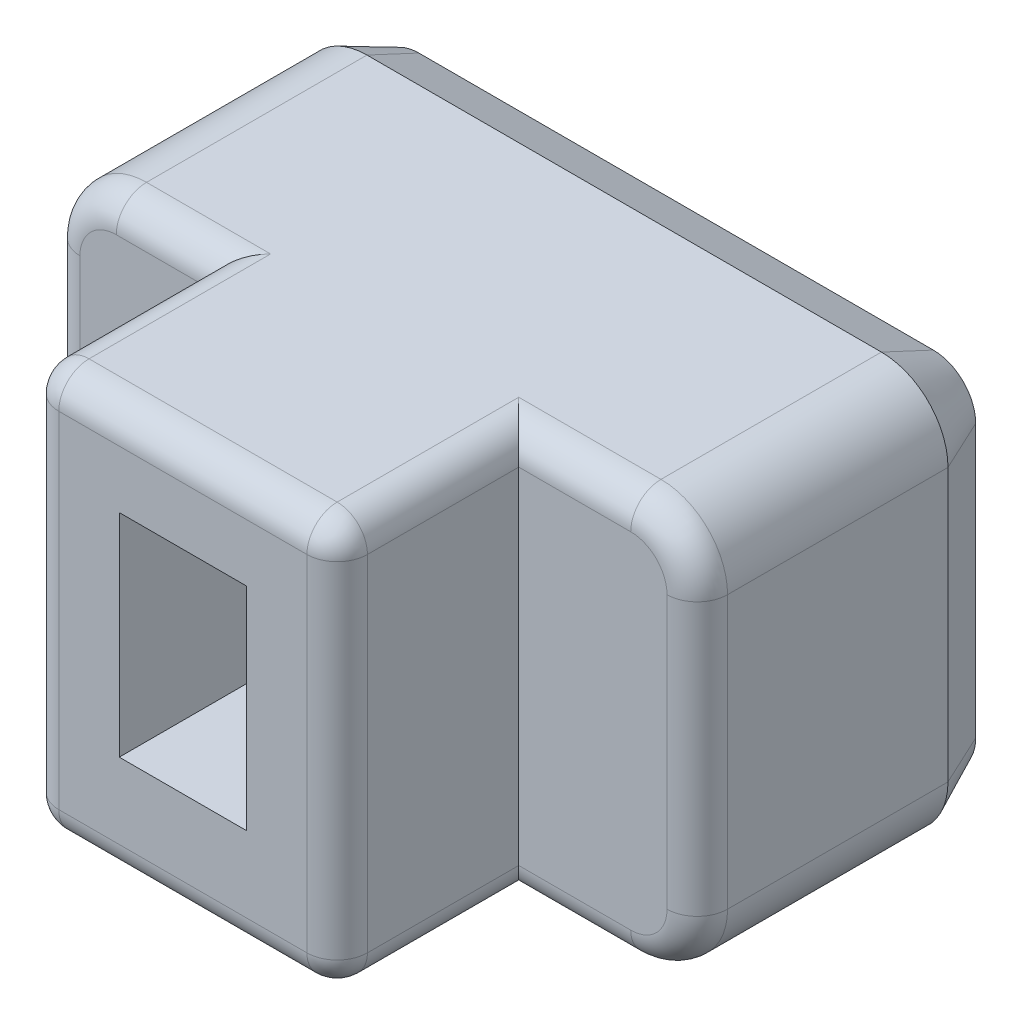
from build123d import *

# Parameters (mm, degrees)
BOSS_EXTRU_1_DEPTH      = 8
ESQUISSE3_W             = 2.1
ESQUISSE3_H             = 3.5
ENL_V_MAT_EXTRU_1_DEPTH = 3
ESQUISSE4_OUTSIDE_W     = 15.69
ESQUISSE4_OUTSIDE_H     = 11.69
ESQUISSE4_OUTSIDE_W_2   = 5.1
ESQUISSE4_OUTSIDE_H_2   = 6.7
ENL_V_MAT_EXTRU_2_DEPTH = 3
CONG_1_R                = 0.5
CHANFREIN1_SIZE         = 0.4
CHANFREIN1_SIZE2        = 0.857802768
ENL_V_MAT_EXTRU_3_DEPTH = 0.2
BOSS_EXTRU_2_DEPTH      = 0.2
BOSS_EXTRU_2_2_DEPTH    = 0.2
BOSS_EXTRU_2_3_DEPTH    = 0.2


with BuildPart() as part:
    # Esquisse2 → Boss.-Extru.1 (new body)
    with BuildSketch(Plane.XY):
        with BuildLine():
            Line((1.1, 0), (9.6, 0))
            ThreePointArc((9.6, 0), (10.377817459, 0.322182541), (10.7, 1.1))
            Line((10.7, 1.1), (10.7, 5.6))
            ThreePointArc((10.7, 5.6), (10.377817459, 6.377817459), (9.6, 6.7))
            Line((9.6, 6.7), (1.1, 6.7))
            ThreePointArc((1.1, 6.7), (0.322182541, 6.377817459), (0, 5.6))
            Line((0, 5.6), (0, 1.1))
            ThreePointArc((0, 1.1), (0.322182541, 0.322182541), (1.1, 0))
        make_face()
    extrude(amount=BOSS_EXTRU_1_DEPTH)

    # Esquisse3 → Enlèv. mat.-Extru.1 (cut)
    with BuildSketch(Plane.XY.offset(8)):
        with Locations((5.2, 3.5)):
            Rectangle(ESQUISSE3_W, ESQUISSE3_H)
    extrude(amount=-ENL_V_MAT_EXTRU_1_DEPTH, mode=Mode.SUBTRACT)

    # Esquisse4 outside → Enlèv. mat.-Extru.2 (cut)
    with BuildSketch(Plane.XY.offset(8)):
        with Locations((5.35, 3.35)):
            Rectangle(ESQUISSE4_OUTSIDE_W, ESQUISSE4_OUTSIDE_H)
        with Locations((5.2, 3.35)):
            Rectangle(ESQUISSE4_OUTSIDE_W_2, ESQUISSE4_OUTSIDE_H_2, mode=Mode.SUBTRACT)
    extrude(amount=-ENL_V_MAT_EXTRU_2_DEPTH, mode=Mode.SUBTRACT)

    # Congé1
    cong_1_edges = [part.edges().sort_by_distance(p)[0] for p in [
        (8.675, 0, 5),
        (10.377817459, 0.322182541, 5),
        (10.7, 3.35, 5),
        (10.377817459, 6.377817459, 5),
        (1.875, 6.7, 5),
        (0.322182541, 6.377817459, 5),
        (1.875, 0, 5),
        (0.322182541, 0.322182541, 5),
        (7.75, 6.7, 6.5),
        (2.65, 6.7, 6.5),
        (7.75, 0, 6.5),
        (2.65, 0, 6.5),
        (2.65, 3.35, 8),
        (5.2, 6.7, 8),
        (7.75, 3.35, 8),
        (5.2, 0, 8),
        (8.675, 6.7, 5),
        (0, 3.35, 5),
    ]]
    fillet(cong_1_edges, radius=CONG_1_R)

    # Chanfrein1
    chanfrein1_edges = [part.edges().sort_by_distance(p)[0] for p in [
        (5.35, 0, 0),
        (10.377817459, 0.322182541, 0),
        (0.322182541, 0.322182541, 0),
        (10.7, 3.35, 0),
        (0, 3.35, 0),
        (10.377817459, 6.377817459, 0),
        (0.322182541, 6.377817459, 0),
        (5.35, 6.7, 0),
    ]]
    chanfrein1_side = [part.faces().sort_by_distance(p)[0] for p in [
        (5.35, 3.35, 0),
    ]]
    chamfer(chanfrein1_edges, length=CHANFREIN1_SIZE, length2=CHANFREIN1_SIZE2, reference=chanfrein1_side[0])

    # Esquisse5 → Enlèv. mat.-Extru.3 (cut)
    with BuildSketch(Plane.XY):
        with BuildLine():
            Line((2.817514503, 5.092998901), (2.643134521, 5.092998901))
            Line((2.643134521, 5.092998901), (1.859587134, 3.00276418))
            add(Edge.make_bspline(
                [(1.859587134, 3.00276418), (1.832279684, 2.929203331), (1.776734704, 2.779576184), (1.695294228, 2.549651593), (1.613961671, 2.310390606), (1.56100836, 2.147204241), (1.534077833, 2.064212364)],
                knots=[0, 0, 0, 0, 0.947748737, 1.92777736, 2.946127352, 4, 4, 4, 4], degree=3))
            Line((1.534077833, 2.064212364), (1.515477302, 2.064212364))
            add(Edge.make_bspline(
                [(1.515477302, 2.064212364), (1.520372189, 2.183298666), (1.52994807, 2.416267545), (1.539870374, 2.758074298), (1.546440558, 3.084374398), (1.547507689, 3.296753009), (1.548028232, 3.40035054)],
                knots=[0, 0, 0, 0, 1.070029531, 2.093301887, 3.069919448, 4, 4, 4, 4], degree=3))
            Line((1.548028232, 3.40035054), (1.548028232, 5.092998901))
            Line((1.548028232, 5.092998901), (1.169042404, 5.092998901))
            Line((1.169042404, 5.092998901), (1.169042404, 1.592998901))
            Line((1.169042404, 1.592998901), (1.715433015, 1.592998901))
            Line((1.715433015, 1.592998901), (2.447828941, 3.573180478))
            add(Edge.make_bspline(
                [(2.447828941, 3.573180478), (2.469461533, 3.632790174), (2.514672823, 3.75737216), (2.581537011, 3.953750489), (2.653347136, 4.166553923), (2.700223151, 4.314793749), (2.724511846, 4.391603861)],
                knots=[0, 0, 0, 0, 0.880724255, 1.840679997, 2.881153501, 4, 4, 4, 4], degree=3))
            Line((2.724511846, 4.391603861), (2.736137178, 4.391603861))
            add(Edge.make_bspline(
                [(2.736137178, 4.391603861), (2.749853222, 4.348726933), (2.776538643, 4.265307186), (2.814999378, 4.143711322), (2.852026734, 4.029978215), (2.888071845, 3.923928876), (2.921903137, 3.825497195), (2.953554522, 3.734420835), (2.98408129, 3.651434256), (3.003521998, 3.598498531), (3.012820083, 3.573180478)],
                knots=[0, 0, 0, 0, 1.25043417, 2.432797927, 3.542461226, 4.57269138, 5.543954559, 6.43358805, 7.250817819, 8, 8, 8, 8], degree=3))
            Line((3.012820083, 3.573180478), (3.745216009, 1.592998901))
            Line((3.745216009, 1.592998901), (4.29160662, 1.592998901))
            Line((4.29160662, 1.592998901), (4.29160662, 5.092998901))
            Line((4.29160662, 5.092998901), (3.912620792, 5.092998901))
            Line((3.912620792, 5.092998901), (3.912620792, 3.40035054))
            add(Edge.make_bspline(
                [(3.912620792, 3.40035054), (3.913244903, 3.298305086), (3.914531118, 3.088001967), (3.919487375, 2.763216242), (3.931119671, 2.419904801), (3.940405694, 2.184852423), (3.945171722, 2.064212364)],
                knots=[0, 0, 0, 0, 0.916160818, 1.888094683, 2.916069754, 4, 4, 4, 4], degree=3))
            Line((3.945171722, 2.064212364), (3.92657119, 2.064212364))
            add(Edge.make_bspline(
                [(3.92657119, 2.064212364), (3.898264381, 2.150792486), (3.843351783, 2.318749931), (3.761739106, 2.562229465), (3.681029008, 2.788347748), (3.62705425, 2.933070672), (3.60106189, 3.00276418)],
                knots=[0, 0, 0, 0, 1.100235793, 2.134355898, 3.101570919, 4, 4, 4, 4], degree=3))
            Line((3.60106189, 3.00276418), (2.817514503, 5.092998901))
        make_face()
        with BuildLine():
            add(Edge.make_bspline(
                [(5.098094662, 2.519150362), (5.098479457, 2.543748085), (5.09922086, 2.591141743), (5.110708693, 2.658611592), (5.12686521, 2.720081012), (5.152521237, 2.774107358), (5.183320539, 2.822524502), (5.217813855, 2.867261442), (5.258966696, 2.906041268), (5.319845774, 2.953064911), (5.40712664, 3.003717061), (5.524214642, 3.049957606), (5.650661745, 3.089057507), (5.737434065, 3.113522336), (5.781664193, 3.125992701)],
                knots=[0, 0, 0, 0, 0.880486965, 1.696478074, 2.446944501, 3.151258593, 3.829523831, 4.502012172, 5.170022751, 5.849803385, 7.256908892, 8.768459035, 10.352798764, 12, 12, 12, 12], degree=3))
            add(Edge.make_bspline(
                [(5.781664193, 3.125992701), (5.841670808, 3.143040851), (5.961479939, 3.177079168), (6.109572139, 3.223336728), (6.224033353, 3.267189913), (6.304744542, 3.305887287), (6.380604036, 3.350604981), (6.45214516, 3.400489678), (6.51780868, 3.458307302), (6.576985073, 3.523894814), (6.629857882, 3.597092218), (6.676294211, 3.678501859), (6.714370019, 3.770574703), (6.739724001, 3.874815211), (6.75533472, 3.990961756), (6.757208254, 4.072239826), (6.758192094, 4.114920956)],
                knots=[0, 0, 0, 0, 1.706742266, 3.407679468, 4.242430161, 5.058020634, 5.853204933, 6.649362358, 7.440579056, 8.241210102, 9.061198638, 9.906297875, 10.800118187, 11.777216625, 12.832761325, 14, 14, 14, 14], degree=3))
            add(Edge.make_bspline(
                [(6.758192094, 4.114920956), (6.757281991, 4.158640741), (6.75551355, 4.24359362), (6.738141025, 4.366171328), (6.710490827, 4.479547926), (6.671691889, 4.583782776), (6.621625705, 4.678086074), (6.564127378, 4.764673025), (6.496883827, 4.841689789), (6.421232518, 4.910411115), (6.337018387, 4.970175567), (6.245174829, 5.021337872), (6.145678785, 5.064275045), (6.038886306, 5.098570422), (5.925720424, 5.125952695), (5.806900789, 5.143750956), (5.683236236, 5.15607339), (5.599049221, 5.157416219), (5.556132749, 5.158100761)],
                knots=[0, 0, 0, 0, 1.159127606, 2.252326411, 3.27615946, 4.249869671, 5.193974946, 6.102490449, 7.001157183, 7.898673524, 8.807628291, 9.734160275, 10.682583241, 11.677288198, 12.706154421, 13.767464238, 14.861908121, 16, 16, 16, 16], degree=3))
            add(Edge.make_bspline(
                [(5.556132749, 5.158100761), (5.515275958, 5.157475502), (5.432576117, 5.156209892), (5.30870202, 5.141961731), (5.186347468, 5.12235001), (5.068980211, 5.096693443), (4.959641152, 5.06755058), (4.862708119, 5.032588899), (4.779659616, 4.99836097), (4.733039646, 4.969525727), (4.712133635, 4.956595004)],
                knots=[0, 0, 0, 0, 1.117668173, 2.262316179, 3.408404461, 4.508127461, 5.549289101, 6.501919885, 7.328208939, 8, 8, 8, 8], degree=3))
            Line((4.712133635, 4.956595004), (4.712133635, 4.567533888))
            add(Edge.make_bspline(
                [(4.712133635, 4.567533888), (4.741616057, 4.582997837), (4.802810542, 4.615095215), (4.901677609, 4.655013594), (5.006863124, 4.691364968), (5.116696761, 4.721344229), (5.22883485, 4.745119233), (5.340807343, 4.763351298), (5.449890722, 4.776918423), (5.521477297, 4.778398446), (5.556132749, 4.779114933)],
                knots=[0, 0, 0, 0, 0.909703881, 1.88820511, 2.911196513, 3.951283487, 4.998564079, 6.043603477, 7.052897759, 8, 8, 8, 8], degree=3))
            add(Edge.make_bspline(
                [(5.556132749, 4.779114933), (5.609197966, 4.777783095), (5.713568373, 4.775163592), (5.840947065, 4.753991765), (5.937798712, 4.731200377), (6.004602927, 4.706425596), (6.067725527, 4.678173866), (6.126013988, 4.643993945), (6.179562574, 4.604255999), (6.2272238, 4.557469175), (6.268439515, 4.503175419), (6.304323887, 4.442558272), (6.333477098, 4.374497247), (6.353111034, 4.298206668), (6.365817786, 4.214292782), (6.366978027, 4.15553109), (6.367580934, 4.124996244)],
                knots=[0, 0, 0, 0, 1.87034002, 3.678646016, 4.542823419, 5.375882515, 6.187380047, 6.979772314, 7.754358122, 8.534072985, 9.326936712, 10.152133513, 11.013664266, 11.928806421, 12.92372774, 14, 14, 14, 14], degree=3))
            add(Edge.make_bspline(
                [(6.367580934, 4.124996244), (6.36677873, 4.099903198), (6.36525, 4.052084319), (6.355302522, 3.983297326), (6.337883497, 3.92135971), (6.312506047, 3.865989077), (6.281024385, 3.817013623), (6.245041056, 3.772165029), (6.203970807, 3.732117974), (6.142754834, 3.683737571), (6.05497561, 3.632852992), (5.93716984, 3.58613705), (5.809563116, 3.547390216), (5.721776296, 3.52289006), (5.677036204, 3.510403684)],
                knots=[0, 0, 0, 0, 0.889177509, 1.694472311, 2.456508881, 3.161117673, 3.844288232, 4.514829322, 5.194556335, 5.872245921, 7.275862128, 8.770198597, 10.353948627, 12, 12, 12, 12], degree=3))
            add(Edge.make_bspline(
                [(5.677036204, 3.510403684), (5.617274334, 3.493921983), (5.498442652, 3.461149444), (5.35177786, 3.415770238), (5.238551835, 3.373096155), (5.158637345, 3.335139901), (5.083468337, 3.291295308), (5.012967187, 3.241825996), (4.947130117, 3.186160003), (4.888720575, 3.121984205), (4.837299312, 3.05014798), (4.792987967, 2.970440013), (4.75515425, 2.881629678), (4.730805865, 2.780877948), (4.714982376, 2.669231771), (4.713111584, 2.591030573), (4.712133635, 2.550151248)],
                knots=[0, 0, 0, 0, 1.731440325, 3.44283011, 4.285652068, 5.108629109, 5.910524492, 6.713230969, 7.511482537, 8.313280534, 9.130226032, 9.973295025, 10.856326095, 11.817060712, 12.858878303, 14, 14, 14, 14], degree=3))
            add(Edge.make_bspline(
                [(4.712133635, 2.550151248), (4.7131776, 2.507220521), (4.715197329, 2.424163689), (4.730617138, 2.304132404), (4.75684638, 2.193434966), (4.793408913, 2.091816425), (4.839304675, 1.999626679), (4.892625974, 1.915317032), (4.953530304, 1.839426682), (5.022635183, 1.772300655), (5.097860725, 1.713095973), (5.179851889, 1.662904624), (5.267228055, 1.619471659), (5.361111342, 1.586059495), (5.459140733, 1.559876835), (5.560710372, 1.541135899), (5.665430722, 1.530280641), (5.736429661, 1.528698035), (5.772363927, 1.527897041)],
                knots=[0, 0, 0, 0, 1.234756564, 2.3888477, 3.473975945, 4.501297612, 5.488398123, 6.43058259, 7.366060614, 8.280490487, 9.196278313, 10.114024079, 11.041318885, 11.99816134, 12.975223422, 13.957668963, 14.966327269, 16, 16, 16, 16], degree=3))
            add(Edge.make_bspline(
                [(5.772363927, 1.527897041), (5.813202891, 1.528414894), (5.89346077, 1.529432593), (6.011763265, 1.539768451), (6.12586223, 1.556836295), (6.235786883, 1.580122977), (6.341108978, 1.608613118), (6.441663931, 1.64265071), (6.53827749, 1.678947205), (6.599989789, 1.707582175), (6.63031344, 1.721652577)],
                knots=[0, 0, 0, 0, 1.104714536, 2.171016076, 3.209933901, 4.224369017, 5.209509432, 6.159944183, 7.095849437, 8, 8, 8, 8], degree=3))
            Line((6.63031344, 1.721652577), (6.63031344, 2.116138848))
            add(Edge.make_bspline(
                [(6.63031344, 2.116138848), (6.565418934, 2.08731366), (6.435678099, 2.029684684), (6.266108425, 1.975243545), (6.126939492, 1.939879235), (6.01787458, 1.92322185), (5.905736878, 1.909636109), (5.829501089, 1.907807312), (5.790964459, 1.906882869)],
                knots=[0, 0, 0, 0, 1.464993217, 2.928898808, 3.670070941, 4.426719255, 5.204718158, 6, 6, 6, 6], degree=3))
            add(Edge.make_bspline(
                [(5.790964459, 1.906882869), (5.762536693, 1.907604431), (5.707382707, 1.909004366), (5.62742592, 1.916153316), (5.553472027, 1.930620029), (5.484972538, 1.948563605), (5.422392103, 1.973137211), (5.365196755, 2.001470654), (5.31332111, 2.034247574), (5.267219743, 2.071664837), (5.226632942, 2.113832812), (5.191577957, 2.160336005), (5.162799591, 2.211662553), (5.138683453, 2.266633945), (5.120366339, 2.325442132), (5.107035799, 2.387414195), (5.099241461, 2.452295992), (5.098480562, 2.496653785), (5.098094662, 2.519150362)],
                knots=[0, 0, 0, 0, 1.296243822, 2.514900931, 3.653549349, 4.727708741, 5.738067187, 6.712369634, 7.633630829, 8.529322939, 9.412149162, 10.295368015, 11.176149746, 12.088486272, 13.027046857, 13.978667069, 14.974857196, 16, 16, 16, 16], degree=3))
        make_face()
        with BuildLine():
            Line((9.195326726, 3.677808467), (8.486181465, 3.677808467))
            Line((8.486181465, 3.677808467), (8.486181465, 3.293397484))
            Line((8.486181465, 3.293397484), (9.574312554, 3.293397484))
            Line((9.574312554, 3.293397484), (9.574312554, 4.986045845))
            add(Edge.make_bspline(
                [(9.574312554, 4.986045845), (9.554337903, 4.996016127), (9.508309318, 5.018991145), (9.425997353, 5.046664397), (9.326767081, 5.075532661), (9.212918745, 5.102247351), (9.088734823, 5.126535451), (8.956184263, 5.143603958), (8.820440785, 5.155856582), (8.729048426, 5.157357737), (8.683812112, 5.158100761)],
                knots=[0, 0, 0, 0, 0.585979414, 1.350301529, 2.276132354, 3.301802694, 4.421346687, 5.59920706, 6.811683744, 8, 8, 8, 8], degree=3))
            add(Edge.make_bspline(
                [(8.683812112, 5.158100761), (8.619148494, 5.156709547), (8.49300037, 5.153995517), (8.310160046, 5.130163786), (8.13844067, 5.092964042), (7.979456218, 5.037919862), (7.831435735, 4.971129826), (7.696488355, 4.889503772), (7.572987937, 4.796645688), (7.463107688, 4.689445276), (7.366063654, 4.569921884), (7.279718683, 4.439099064), (7.208209438, 4.294780042), (7.148414287, 4.139642686), (7.10250499, 3.973907841), (7.067845736, 3.799158239), (7.048934363, 3.614673902), (7.046092718, 3.488742886), (7.044640278, 3.424376226)],
                knots=[0, 0, 0, 0, 1.146148901, 2.235948753, 3.263977738, 4.256307499, 5.213590835, 6.138269925, 7.047143522, 7.947736641, 8.852792543, 9.772682079, 10.721211655, 11.702953654, 12.716665434, 13.766898494, 14.858603004, 16, 16, 16, 16], degree=3))
            add(Edge.make_bspline(
                [(7.044640278, 3.424376226), (7.046063576, 3.354300357), (7.048844883, 3.21736304), (7.072535425, 3.016612658), (7.111842754, 2.826044903), (7.166207315, 2.645564588), (7.234041196, 2.476480104), (7.315747278, 2.319604891), (7.410735069, 2.175623208), (7.517693111, 2.044195798), (7.636911901, 1.926389957), (7.767828093, 1.82299762), (7.909496666, 1.733292142), (8.061866497, 1.658987872), (8.223520824, 1.599637052), (8.39405789, 1.558111033), (8.572480471, 1.532774358), (8.694061405, 1.529541203), (8.755889171, 1.527897041)],
                knots=[0, 0, 0, 0, 1.170978058, 2.288242658, 3.373061366, 4.419447092, 5.43457523, 6.413784157, 7.370679712, 8.312808504, 9.241030757, 10.166265276, 11.09588253, 12.038278457, 12.994501538, 13.968469652, 14.966902308, 16, 16, 16, 16], degree=3))
            add(Edge.make_bspline(
                [(8.755889171, 1.527897041), (8.789994557, 1.528445553), (8.858259087, 1.529543442), (8.959990706, 1.535241084), (9.059140273, 1.547474272), (9.154194187, 1.561494817), (9.243340484, 1.580377517), (9.325308622, 1.601309301), (9.397408333, 1.625337025), (9.440613547, 1.644624609), (9.460384299, 1.653450628)],
                knots=[0, 0, 0, 0, 1.136075315, 2.27394134, 3.391388784, 4.462283479, 5.473109321, 6.424781878, 7.279178486, 8, 8, 8, 8], degree=3))
            Line((9.460384299, 1.653450628), (9.460384299, 2.03011139))
            add(Edge.make_bspline(
                [(9.460384299, 2.03011139), (9.436477281, 2.021216258), (9.387112841, 2.002849134), (9.308852946, 1.981876261), (9.226399112, 1.958931325), (9.109238471, 1.935175858), (8.95906135, 1.911477231), (8.837374156, 1.908409546), (8.776814769, 1.906882869)],
                knots=[0, 0, 0, 0, 0.65742795, 1.357490991, 2.087898976, 2.864030287, 4.439339425, 6, 6, 6, 6], degree=3))
            add(Edge.make_bspline(
                [(8.776814769, 1.906882869), (8.73309505, 1.907832375), (8.646349541, 1.909716317), (8.518021322, 1.92765633), (8.39261655, 1.955243693), (8.270855131, 1.994867158), (8.153729798, 2.04569206), (8.043442846, 2.108781533), (7.93995472, 2.182927149), (7.844637741, 2.269512843), (7.756449948, 2.367025534), (7.67926521, 2.477553323), (7.609401329, 2.598164836), (7.550954692, 2.731319812), (7.502238837, 2.875733898), (7.468729147, 3.032496165), (7.448405384, 3.200890558), (7.445863796, 3.31710454), (7.444551704, 3.377099875)],
                knots=[0, 0, 0, 0, 0.939117775, 1.863329679, 2.779299697, 3.695824843, 4.610784674, 5.51843797, 6.421392248, 7.34127464, 8.280966674, 9.240717944, 10.23307823, 11.272042469, 12.360603596, 13.503011429, 14.710932506, 16, 16, 16, 16], degree=3))
            add(Edge.make_bspline(
                [(7.444551704, 3.377099875), (7.445421, 3.435793474), (7.447098508, 3.549056324), (7.464772977, 3.712750977), (7.491644211, 3.864173966), (7.531542178, 4.003126934), (7.581261211, 4.129830741), (7.639368607, 4.245819722), (7.707439042, 4.350143479), (7.785846886, 4.442231757), (7.872402683, 4.523739913), (7.968203701, 4.593723734), (8.072807596, 4.652319418), (8.186083995, 4.698392677), (8.306177671, 4.73494513), (8.433410226, 4.76014165), (8.56689956, 4.775996038), (8.658190694, 4.778061703), (8.704737709, 4.779114933)],
                knots=[0, 0, 0, 0, 1.309777504, 2.527518125, 3.6711271, 4.738994566, 5.748914077, 6.705800728, 7.630353787, 8.522389362, 9.39963012, 10.278613241, 11.164231144, 12.069241185, 13.003350139, 13.96247614, 14.961118681, 16, 16, 16, 16], degree=3))
            add(Edge.make_bspline(
                [(8.704737709, 4.779114933), (8.748694815, 4.778484222), (8.836269585, 4.77722767), (8.964208569, 4.763822027), (9.084535915, 4.747315095), (9.159809318, 4.727848452), (9.195326726, 4.718663206)],
                knots=[0, 0, 0, 0, 1.063710201, 2.1192063, 3.112556144, 4, 4, 4, 4], degree=3))
            Line((9.195326726, 4.718663206), (9.195326726, 3.677808467))
        make_face()
    extrude(amount=ENL_V_MAT_EXTRU_3_DEPTH, mode=Mode.SUBTRACT)


with BuildPart() as body_2:
    # Esquisse5_4 → Boss.-Extru.2 (new body)
    with BuildSketch(Plane.XY):
        with BuildLine():
            Line((2.817514503, 5.092998901), (2.643134521, 5.092998901))
            Line((2.643134521, 5.092998901), (1.859587134, 3.00276418))
            add(Edge.make_bspline(
                [(1.859587134, 3.00276418), (1.832279684, 2.929203331), (1.776734704, 2.779576184), (1.695294228, 2.549651593), (1.613961671, 2.310390606), (1.56100836, 2.147204241), (1.534077833, 2.064212364)],
                knots=[0, 0, 0, 0, 0.947748737, 1.92777736, 2.946127352, 4, 4, 4, 4], degree=3))
            Line((1.534077833, 2.064212364), (1.515477302, 2.064212364))
            add(Edge.make_bspline(
                [(1.515477302, 2.064212364), (1.520372189, 2.183298666), (1.52994807, 2.416267545), (1.539870374, 2.758074298), (1.546440558, 3.084374398), (1.547507689, 3.296753009), (1.548028232, 3.40035054)],
                knots=[0, 0, 0, 0, 1.070029531, 2.093301887, 3.069919448, 4, 4, 4, 4], degree=3))
            Line((1.548028232, 3.40035054), (1.548028232, 5.092998901))
            Line((1.548028232, 5.092998901), (1.169042404, 5.092998901))
            Line((1.169042404, 5.092998901), (1.169042404, 1.592998901))
            Line((1.169042404, 1.592998901), (1.715433015, 1.592998901))
            Line((1.715433015, 1.592998901), (2.447828941, 3.573180478))
            add(Edge.make_bspline(
                [(2.447828941, 3.573180478), (2.469461533, 3.632790174), (2.514672823, 3.75737216), (2.581537011, 3.953750489), (2.653347136, 4.166553923), (2.700223151, 4.314793749), (2.724511846, 4.391603861)],
                knots=[0, 0, 0, 0, 0.880724255, 1.840679997, 2.881153501, 4, 4, 4, 4], degree=3))
            Line((2.724511846, 4.391603861), (2.736137178, 4.391603861))
            add(Edge.make_bspline(
                [(2.736137178, 4.391603861), (2.749853222, 4.348726933), (2.776538643, 4.265307186), (2.814999378, 4.143711322), (2.852026734, 4.029978215), (2.888071845, 3.923928876), (2.921903137, 3.825497195), (2.953554522, 3.734420835), (2.98408129, 3.651434256), (3.003521998, 3.598498531), (3.012820083, 3.573180478)],
                knots=[0, 0, 0, 0, 1.25043417, 2.432797927, 3.542461226, 4.57269138, 5.543954559, 6.43358805, 7.250817819, 8, 8, 8, 8], degree=3))
            Line((3.012820083, 3.573180478), (3.745216009, 1.592998901))
            Line((3.745216009, 1.592998901), (4.29160662, 1.592998901))
            Line((4.29160662, 1.592998901), (4.29160662, 5.092998901))
            Line((4.29160662, 5.092998901), (3.912620792, 5.092998901))
            Line((3.912620792, 5.092998901), (3.912620792, 3.40035054))
            add(Edge.make_bspline(
                [(3.912620792, 3.40035054), (3.913244903, 3.298305086), (3.914531118, 3.088001967), (3.919487375, 2.763216242), (3.931119671, 2.419904801), (3.940405694, 2.184852423), (3.945171722, 2.064212364)],
                knots=[0, 0, 0, 0, 0.916160818, 1.888094683, 2.916069754, 4, 4, 4, 4], degree=3))
            Line((3.945171722, 2.064212364), (3.92657119, 2.064212364))
            add(Edge.make_bspline(
                [(3.92657119, 2.064212364), (3.898264381, 2.150792486), (3.843351783, 2.318749931), (3.761739106, 2.562229465), (3.681029008, 2.788347748), (3.62705425, 2.933070672), (3.60106189, 3.00276418)],
                knots=[0, 0, 0, 0, 1.100235793, 2.134355898, 3.101570919, 4, 4, 4, 4], degree=3))
            Line((3.60106189, 3.00276418), (2.817514503, 5.092998901))
        make_face()
    extrude(amount=-BOSS_EXTRU_2_DEPTH)


with BuildPart() as body_3:
    # Esquisse5_4 → Boss.-Extru.2 2 (new body)
    with BuildSketch(Plane.XY):
        with BuildLine():
            add(Edge.make_bspline(
                [(5.098094662, 2.519150362), (5.098479457, 2.543748085), (5.09922086, 2.591141743), (5.110708693, 2.658611592), (5.12686521, 2.720081012), (5.152521237, 2.774107358), (5.183320539, 2.822524502), (5.217813855, 2.867261442), (5.258966696, 2.906041268), (5.319845774, 2.953064911), (5.40712664, 3.003717061), (5.524214642, 3.049957606), (5.650661745, 3.089057507), (5.737434065, 3.113522336), (5.781664193, 3.125992701)],
                knots=[0, 0, 0, 0, 0.880486965, 1.696478074, 2.446944501, 3.151258593, 3.829523831, 4.502012172, 5.170022751, 5.849803385, 7.256908892, 8.768459035, 10.352798764, 12, 12, 12, 12], degree=3))
            add(Edge.make_bspline(
                [(5.781664193, 3.125992701), (5.841670808, 3.143040851), (5.961479939, 3.177079168), (6.109572139, 3.223336728), (6.224033353, 3.267189913), (6.304744542, 3.305887287), (6.380604036, 3.350604981), (6.45214516, 3.400489678), (6.51780868, 3.458307302), (6.576985073, 3.523894814), (6.629857882, 3.597092218), (6.676294211, 3.678501859), (6.714370019, 3.770574703), (6.739724001, 3.874815211), (6.75533472, 3.990961756), (6.757208254, 4.072239826), (6.758192094, 4.114920956)],
                knots=[0, 0, 0, 0, 1.706742266, 3.407679468, 4.242430161, 5.058020634, 5.853204933, 6.649362358, 7.440579056, 8.241210102, 9.061198638, 9.906297875, 10.800118187, 11.777216625, 12.832761325, 14, 14, 14, 14], degree=3))
            add(Edge.make_bspline(
                [(6.758192094, 4.114920956), (6.757281991, 4.158640741), (6.75551355, 4.24359362), (6.738141025, 4.366171328), (6.710490827, 4.479547926), (6.671691889, 4.583782776), (6.621625705, 4.678086074), (6.564127378, 4.764673025), (6.496883827, 4.841689789), (6.421232518, 4.910411115), (6.337018387, 4.970175567), (6.245174829, 5.021337872), (6.145678785, 5.064275045), (6.038886306, 5.098570422), (5.925720424, 5.125952695), (5.806900789, 5.143750956), (5.683236236, 5.15607339), (5.599049221, 5.157416219), (5.556132749, 5.158100761)],
                knots=[0, 0, 0, 0, 1.159127606, 2.252326411, 3.27615946, 4.249869671, 5.193974946, 6.102490449, 7.001157183, 7.898673524, 8.807628291, 9.734160275, 10.682583241, 11.677288198, 12.706154421, 13.767464238, 14.861908121, 16, 16, 16, 16], degree=3))
            add(Edge.make_bspline(
                [(5.556132749, 5.158100761), (5.515275958, 5.157475502), (5.432576117, 5.156209892), (5.30870202, 5.141961731), (5.186347468, 5.12235001), (5.068980211, 5.096693443), (4.959641152, 5.06755058), (4.862708119, 5.032588899), (4.779659616, 4.99836097), (4.733039646, 4.969525727), (4.712133635, 4.956595004)],
                knots=[0, 0, 0, 0, 1.117668173, 2.262316179, 3.408404461, 4.508127461, 5.549289101, 6.501919885, 7.328208939, 8, 8, 8, 8], degree=3))
            Line((4.712133635, 4.956595004), (4.712133635, 4.567533888))
            add(Edge.make_bspline(
                [(4.712133635, 4.567533888), (4.741616057, 4.582997837), (4.802810542, 4.615095215), (4.901677609, 4.655013594), (5.006863124, 4.691364968), (5.116696761, 4.721344229), (5.22883485, 4.745119233), (5.340807343, 4.763351298), (5.449890722, 4.776918423), (5.521477297, 4.778398446), (5.556132749, 4.779114933)],
                knots=[0, 0, 0, 0, 0.909703881, 1.88820511, 2.911196513, 3.951283487, 4.998564079, 6.043603477, 7.052897759, 8, 8, 8, 8], degree=3))
            add(Edge.make_bspline(
                [(5.556132749, 4.779114933), (5.609197966, 4.777783095), (5.713568373, 4.775163592), (5.840947065, 4.753991765), (5.937798712, 4.731200377), (6.004602927, 4.706425596), (6.067725527, 4.678173866), (6.126013988, 4.643993945), (6.179562574, 4.604255999), (6.2272238, 4.557469175), (6.268439515, 4.503175419), (6.304323887, 4.442558272), (6.333477098, 4.374497247), (6.353111034, 4.298206668), (6.365817786, 4.214292782), (6.366978027, 4.15553109), (6.367580934, 4.124996244)],
                knots=[0, 0, 0, 0, 1.87034002, 3.678646016, 4.542823419, 5.375882515, 6.187380047, 6.979772314, 7.754358122, 8.534072985, 9.326936712, 10.152133513, 11.013664266, 11.928806421, 12.92372774, 14, 14, 14, 14], degree=3))
            add(Edge.make_bspline(
                [(6.367580934, 4.124996244), (6.36677873, 4.099903198), (6.36525, 4.052084319), (6.355302522, 3.983297326), (6.337883497, 3.92135971), (6.312506047, 3.865989077), (6.281024385, 3.817013623), (6.245041056, 3.772165029), (6.203970807, 3.732117974), (6.142754834, 3.683737571), (6.05497561, 3.632852992), (5.93716984, 3.58613705), (5.809563116, 3.547390216), (5.721776296, 3.52289006), (5.677036204, 3.510403684)],
                knots=[0, 0, 0, 0, 0.889177509, 1.694472311, 2.456508881, 3.161117673, 3.844288232, 4.514829322, 5.194556335, 5.872245921, 7.275862128, 8.770198597, 10.353948627, 12, 12, 12, 12], degree=3))
            add(Edge.make_bspline(
                [(5.677036204, 3.510403684), (5.617274334, 3.493921983), (5.498442652, 3.461149444), (5.35177786, 3.415770238), (5.238551835, 3.373096155), (5.158637345, 3.335139901), (5.083468337, 3.291295308), (5.012967187, 3.241825996), (4.947130117, 3.186160003), (4.888720575, 3.121984205), (4.837299312, 3.05014798), (4.792987967, 2.970440013), (4.75515425, 2.881629678), (4.730805865, 2.780877948), (4.714982376, 2.669231771), (4.713111584, 2.591030573), (4.712133635, 2.550151248)],
                knots=[0, 0, 0, 0, 1.731440325, 3.44283011, 4.285652068, 5.108629109, 5.910524492, 6.713230969, 7.511482537, 8.313280534, 9.130226032, 9.973295025, 10.856326095, 11.817060712, 12.858878303, 14, 14, 14, 14], degree=3))
            add(Edge.make_bspline(
                [(4.712133635, 2.550151248), (4.7131776, 2.507220521), (4.715197329, 2.424163689), (4.730617138, 2.304132404), (4.75684638, 2.193434966), (4.793408913, 2.091816425), (4.839304675, 1.999626679), (4.892625974, 1.915317032), (4.953530304, 1.839426682), (5.022635183, 1.772300655), (5.097860725, 1.713095973), (5.179851889, 1.662904624), (5.267228055, 1.619471659), (5.361111342, 1.586059495), (5.459140733, 1.559876835), (5.560710372, 1.541135899), (5.665430722, 1.530280641), (5.736429661, 1.528698035), (5.772363927, 1.527897041)],
                knots=[0, 0, 0, 0, 1.234756564, 2.3888477, 3.473975945, 4.501297612, 5.488398123, 6.43058259, 7.366060614, 8.280490487, 9.196278313, 10.114024079, 11.041318885, 11.99816134, 12.975223422, 13.957668963, 14.966327269, 16, 16, 16, 16], degree=3))
            add(Edge.make_bspline(
                [(5.772363927, 1.527897041), (5.813202891, 1.528414894), (5.89346077, 1.529432593), (6.011763265, 1.539768451), (6.12586223, 1.556836295), (6.235786883, 1.580122977), (6.341108978, 1.608613118), (6.441663931, 1.64265071), (6.53827749, 1.678947205), (6.599989789, 1.707582175), (6.63031344, 1.721652577)],
                knots=[0, 0, 0, 0, 1.104714536, 2.171016076, 3.209933901, 4.224369017, 5.209509432, 6.159944183, 7.095849437, 8, 8, 8, 8], degree=3))
            Line((6.63031344, 1.721652577), (6.63031344, 2.116138848))
            add(Edge.make_bspline(
                [(6.63031344, 2.116138848), (6.565418934, 2.08731366), (6.435678099, 2.029684684), (6.266108425, 1.975243545), (6.126939492, 1.939879235), (6.01787458, 1.92322185), (5.905736878, 1.909636109), (5.829501089, 1.907807312), (5.790964459, 1.906882869)],
                knots=[0, 0, 0, 0, 1.464993217, 2.928898808, 3.670070941, 4.426719255, 5.204718158, 6, 6, 6, 6], degree=3))
            add(Edge.make_bspline(
                [(5.790964459, 1.906882869), (5.762536693, 1.907604431), (5.707382707, 1.909004366), (5.62742592, 1.916153316), (5.553472027, 1.930620029), (5.484972538, 1.948563605), (5.422392103, 1.973137211), (5.365196755, 2.001470654), (5.31332111, 2.034247574), (5.267219743, 2.071664837), (5.226632942, 2.113832812), (5.191577957, 2.160336005), (5.162799591, 2.211662553), (5.138683453, 2.266633945), (5.120366339, 2.325442132), (5.107035799, 2.387414195), (5.099241461, 2.452295992), (5.098480562, 2.496653785), (5.098094662, 2.519150362)],
                knots=[0, 0, 0, 0, 1.296243822, 2.514900931, 3.653549349, 4.727708741, 5.738067187, 6.712369634, 7.633630829, 8.529322939, 9.412149162, 10.295368015, 11.176149746, 12.088486272, 13.027046857, 13.978667069, 14.974857196, 16, 16, 16, 16], degree=3))
        make_face()
    extrude(amount=-BOSS_EXTRU_2_2_DEPTH)


with BuildPart() as body_4:
    # Esquisse5_4 → Boss.-Extru.2 3 (new body)
    with BuildSketch(Plane.XY):
        with BuildLine():
            Line((9.195326726, 3.677808467), (8.486181465, 3.677808467))
            Line((8.486181465, 3.677808467), (8.486181465, 3.293397484))
            Line((8.486181465, 3.293397484), (9.574312554, 3.293397484))
            Line((9.574312554, 3.293397484), (9.574312554, 4.986045845))
            add(Edge.make_bspline(
                [(9.574312554, 4.986045845), (9.554337903, 4.996016127), (9.508309318, 5.018991145), (9.425997353, 5.046664397), (9.326767081, 5.075532661), (9.212918745, 5.102247351), (9.088734823, 5.126535451), (8.956184263, 5.143603958), (8.820440785, 5.155856582), (8.729048426, 5.157357737), (8.683812112, 5.158100761)],
                knots=[0, 0, 0, 0, 0.585979414, 1.350301529, 2.276132354, 3.301802694, 4.421346687, 5.59920706, 6.811683744, 8, 8, 8, 8], degree=3))
            add(Edge.make_bspline(
                [(8.683812112, 5.158100761), (8.619148494, 5.156709547), (8.49300037, 5.153995517), (8.310160046, 5.130163786), (8.13844067, 5.092964042), (7.979456218, 5.037919862), (7.831435735, 4.971129826), (7.696488355, 4.889503772), (7.572987937, 4.796645688), (7.463107688, 4.689445276), (7.366063654, 4.569921884), (7.279718683, 4.439099064), (7.208209438, 4.294780042), (7.148414287, 4.139642686), (7.10250499, 3.973907841), (7.067845736, 3.799158239), (7.048934363, 3.614673902), (7.046092718, 3.488742886), (7.044640278, 3.424376226)],
                knots=[0, 0, 0, 0, 1.146148901, 2.235948753, 3.263977738, 4.256307499, 5.213590835, 6.138269925, 7.047143522, 7.947736641, 8.852792543, 9.772682079, 10.721211655, 11.702953654, 12.716665434, 13.766898494, 14.858603004, 16, 16, 16, 16], degree=3))
            add(Edge.make_bspline(
                [(7.044640278, 3.424376226), (7.046063576, 3.354300357), (7.048844883, 3.21736304), (7.072535425, 3.016612658), (7.111842754, 2.826044903), (7.166207315, 2.645564588), (7.234041196, 2.476480104), (7.315747278, 2.319604891), (7.410735069, 2.175623208), (7.517693111, 2.044195798), (7.636911901, 1.926389957), (7.767828093, 1.82299762), (7.909496666, 1.733292142), (8.061866497, 1.658987872), (8.223520824, 1.599637052), (8.39405789, 1.558111033), (8.572480471, 1.532774358), (8.694061405, 1.529541203), (8.755889171, 1.527897041)],
                knots=[0, 0, 0, 0, 1.170978058, 2.288242658, 3.373061366, 4.419447092, 5.43457523, 6.413784157, 7.370679712, 8.312808504, 9.241030757, 10.166265276, 11.09588253, 12.038278457, 12.994501538, 13.968469652, 14.966902308, 16, 16, 16, 16], degree=3))
            add(Edge.make_bspline(
                [(8.755889171, 1.527897041), (8.789994557, 1.528445553), (8.858259087, 1.529543442), (8.959990706, 1.535241084), (9.059140273, 1.547474272), (9.154194187, 1.561494817), (9.243340484, 1.580377517), (9.325308622, 1.601309301), (9.397408333, 1.625337025), (9.440613547, 1.644624609), (9.460384299, 1.653450628)],
                knots=[0, 0, 0, 0, 1.136075315, 2.27394134, 3.391388784, 4.462283479, 5.473109321, 6.424781878, 7.279178486, 8, 8, 8, 8], degree=3))
            Line((9.460384299, 1.653450628), (9.460384299, 2.03011139))
            add(Edge.make_bspline(
                [(9.460384299, 2.03011139), (9.436477281, 2.021216258), (9.387112841, 2.002849134), (9.308852946, 1.981876261), (9.226399112, 1.958931325), (9.109238471, 1.935175858), (8.95906135, 1.911477231), (8.837374156, 1.908409546), (8.776814769, 1.906882869)],
                knots=[0, 0, 0, 0, 0.65742795, 1.357490991, 2.087898976, 2.864030287, 4.439339425, 6, 6, 6, 6], degree=3))
            add(Edge.make_bspline(
                [(8.776814769, 1.906882869), (8.73309505, 1.907832375), (8.646349541, 1.909716317), (8.518021322, 1.92765633), (8.39261655, 1.955243693), (8.270855131, 1.994867158), (8.153729798, 2.04569206), (8.043442846, 2.108781533), (7.93995472, 2.182927149), (7.844637741, 2.269512843), (7.756449948, 2.367025534), (7.67926521, 2.477553323), (7.609401329, 2.598164836), (7.550954692, 2.731319812), (7.502238837, 2.875733898), (7.468729147, 3.032496165), (7.448405384, 3.200890558), (7.445863796, 3.31710454), (7.444551704, 3.377099875)],
                knots=[0, 0, 0, 0, 0.939117775, 1.863329679, 2.779299697, 3.695824843, 4.610784674, 5.51843797, 6.421392248, 7.34127464, 8.280966674, 9.240717944, 10.23307823, 11.272042469, 12.360603596, 13.503011429, 14.710932506, 16, 16, 16, 16], degree=3))
            add(Edge.make_bspline(
                [(7.444551704, 3.377099875), (7.445421, 3.435793474), (7.447098508, 3.549056324), (7.464772977, 3.712750977), (7.491644211, 3.864173966), (7.531542178, 4.003126934), (7.581261211, 4.129830741), (7.639368607, 4.245819722), (7.707439042, 4.350143479), (7.785846886, 4.442231757), (7.872402683, 4.523739913), (7.968203701, 4.593723734), (8.072807596, 4.652319418), (8.186083995, 4.698392677), (8.306177671, 4.73494513), (8.433410226, 4.76014165), (8.56689956, 4.775996038), (8.658190694, 4.778061703), (8.704737709, 4.779114933)],
                knots=[0, 0, 0, 0, 1.309777504, 2.527518125, 3.6711271, 4.738994566, 5.748914077, 6.705800728, 7.630353787, 8.522389362, 9.39963012, 10.278613241, 11.164231144, 12.069241185, 13.003350139, 13.96247614, 14.961118681, 16, 16, 16, 16], degree=3))
            add(Edge.make_bspline(
                [(8.704737709, 4.779114933), (8.748694815, 4.778484222), (8.836269585, 4.77722767), (8.964208569, 4.763822027), (9.084535915, 4.747315095), (9.159809318, 4.727848452), (9.195326726, 4.718663206)],
                knots=[0, 0, 0, 0, 1.063710201, 2.1192063, 3.112556144, 4, 4, 4, 4], degree=3))
            Line((9.195326726, 4.718663206), (9.195326726, 3.677808467))
        make_face()
    extrude(amount=-BOSS_EXTRU_2_3_DEPTH)


solid = Compound([part.part, body_2.part, body_3.part, body_4.part])
